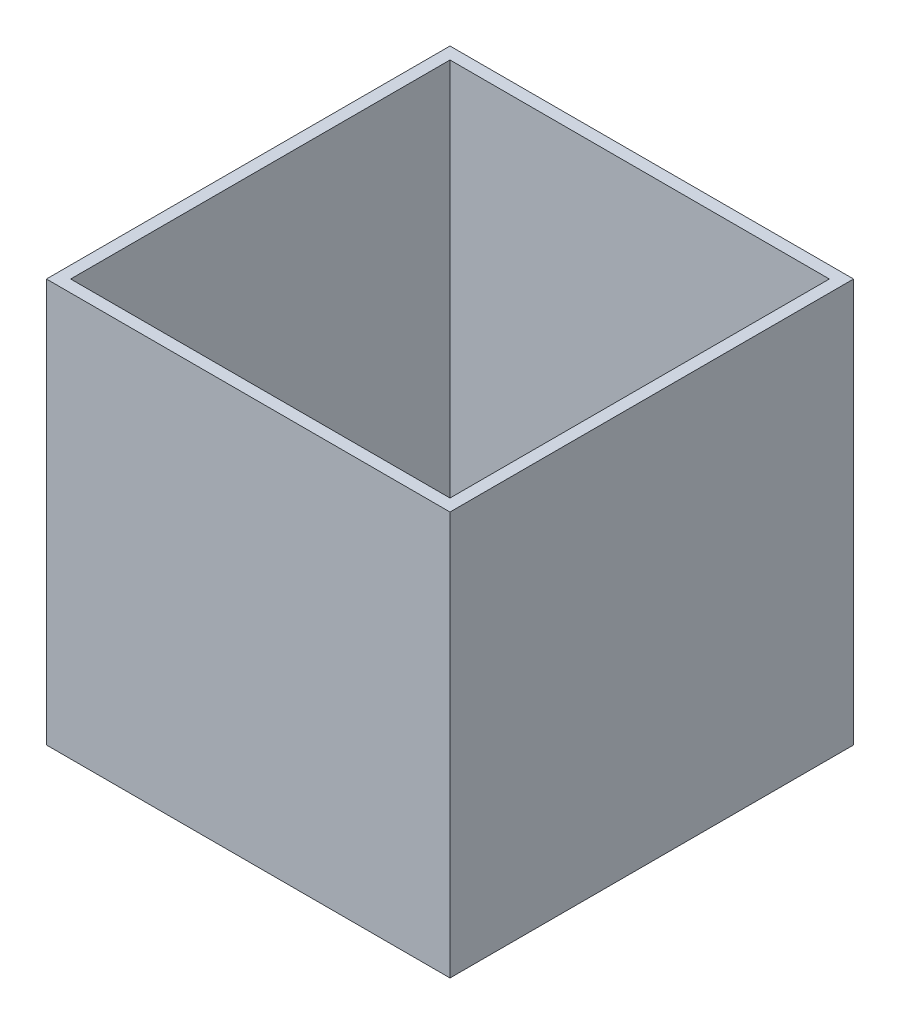
from build123d import *

# Parameters (mm, degrees)
SKETCH1_W           = 1000
SKETCH1_H           = 1000
BOSS_EXTRUDE1_DEPTH = 1000
SHELL1_T            = -30
SKETCH4_W           = 140
SKETCH4_H           = 140
BOSS_EXTRUDE2_DEPTH = 200
SKETCH5_W           = 60
SKETCH5_H           = 50
BOSS_EXTRUDE3_DEPTH = 20
SKETCH6_R           = 10
CUT_EXTRUDE5_DEPTH  = 80


with BuildPart() as part:
    # Sketch1 → Boss-Extrude1 (new body)
    with BuildSketch(Plane(origin=(0, 0, 0), x_dir=(1, 0, 0), z_dir=(0, 1, 0))):
        with Locations((410.346861064, 441.605744818)):
            Rectangle(SKETCH1_W, SKETCH1_H)
    extrude(amount=BOSS_EXTRUDE1_DEPTH)

    # Shell1
    shell1_openings = [part.faces().sort_by_distance(p)[0] for p in [
        (410.346861064, 1000, -441.605744818),
    ]]
    offset(amount=SHELL1_T, openings=shell1_openings, kind=Kind.INTERSECTION)

    # Sketch4 → Boss-Extrude2 (add)
    with BuildSketch(Plane(origin=(0, 30, 0), x_dir=(1, 0, 0), z_dir=(0, 1, 0))):
        with Locations((410.346861064, 441.605744818)):
            Rectangle(SKETCH4_W, SKETCH4_H)
    extrude(amount=BOSS_EXTRUDE2_DEPTH)

    # Sketch5 → Boss-Extrude3 (add)
    with BuildSketch(Plane(origin=(480.346861064, 0, 0), x_dir=(0, 0, -1), z_dir=(1, 0, 0))):
        with Locations((401.605744818, 55)):
            Rectangle(SKETCH5_W, SKETCH5_H)
    extrude(amount=BOSS_EXTRUDE3_DEPTH)

    # Sketch6 → Cut-Extrude5 (cut)
    with BuildSketch(Plane(origin=(0, 230, 0), x_dir=(1, 0, 0), z_dir=(0, 1, 0))):
        with Locations((410.346861064, 491.605744818)):
            Circle(SKETCH6_R)
        with Locations((360.346861064, 441.605744818)):
            Circle(SKETCH6_R)
        with Locations((410.346861064, 391.605744818)):
            Circle(SKETCH6_R)
        with Locations((460.346861064, 441.605744818)):
            Circle(SKETCH6_R)
    extrude(amount=-CUT_EXTRUDE5_DEPTH, mode=Mode.SUBTRACT)


solid = part.part
